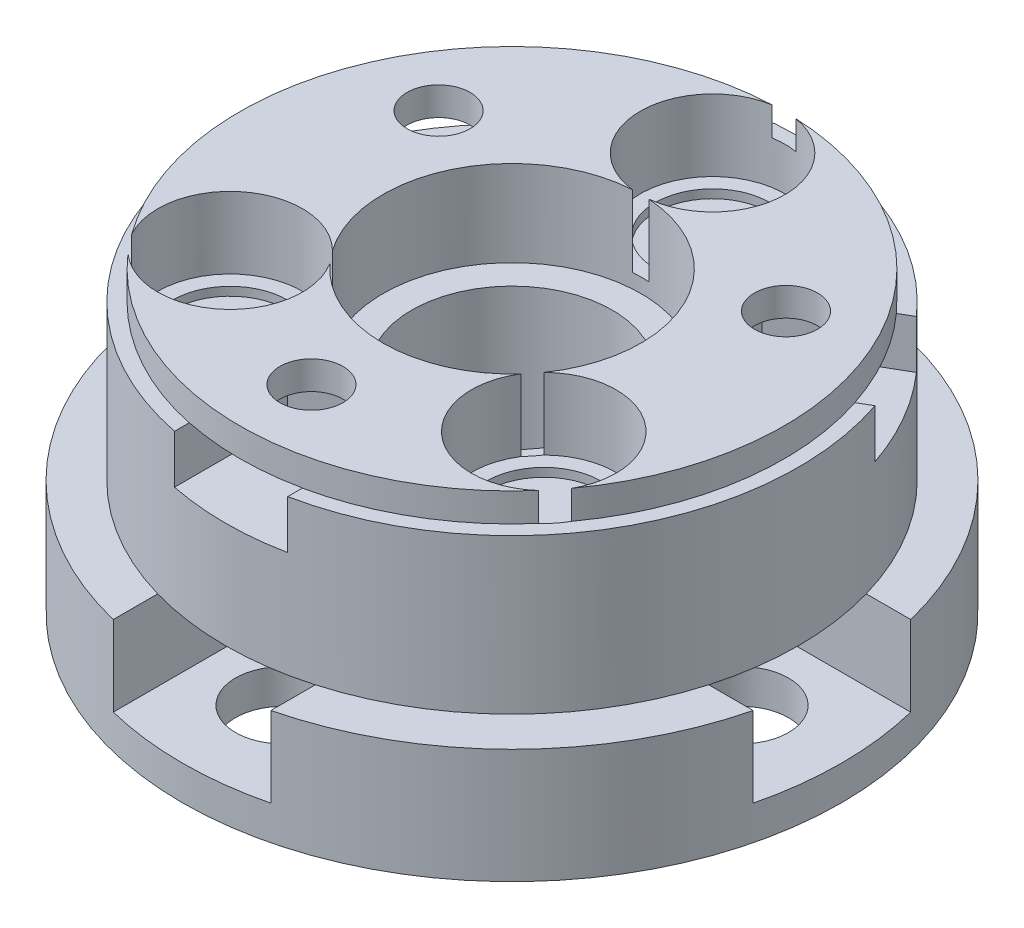
from build123d import *

# Parameters (mm, degrees)
SKETCH2_R           = 11.5
BOSS_EXTRUDE1_DEPTH = 1
SKETCH3_R           = 10
BOSS_EXTRUDE2_DEPTH = 4
SKETCH4_R           = 2.525
CUT_EXTRUDE1_DEPTH  = 17.984370982
SKETCH5_R           = 2
CUT_EXTRUDE2_DEPTH  = 0.3
CIRPATTERN1_COUNT   = 14
SKETCH7_R           = 10
SKETCH7_R_2         = 2.525
BOSS_EXTRUDE4_DEPTH = 1.5
BOSS_EXTRUDE3_DEPTH = 0.998
SKETCH8_R           = 1.1
CUT_EXTRUDE3_DEPTH  = 2.69
CUT_EXTRUDE4_DEPTH  = 1.7
CIRPATTERN2_COUNT   = 3
SKETCH11_R          = 11.5
BOSS_EXTRUDE5_DEPTH = 3
SKETCH12_R          = 1.65
CUT_EXTRUDE5_DEPTH  = 4
CUT_EXTRUDE6_DEPTH  = 2.8
CIRPATTERN3_COUNT   = 4
SKETCH16_R          = 4.5
CUT_EXTRUDE9_DEPTH  = 2
SKETCH17_R          = 3.5
CUT_EXTRUDE10_DEPTH = 18.866109191


with BuildPart() as part:
    # Sketch2 → Boss-Extrude1 (new body)
    with BuildSketch(Plane(origin=(0, 0, 0), x_dir=(1, 0, 0), z_dir=(0, 1, 0))):
        with Locations(Location((0, 0, 0), (0, 0, 270))):
            Circle(SKETCH2_R)
    extrude(amount=BOSS_EXTRUDE1_DEPTH)

    # Sketch3 → Boss-Extrude2 (add)
    with BuildSketch(Plane(origin=(0, 1, 0), x_dir=(1, 0, 0), z_dir=(0, 1, 0))):
        with Locations(Location((0, 0, 0), (0, 0, 270))):
            Circle(SKETCH3_R)
    extrude(amount=BOSS_EXTRUDE2_DEPTH)

    # Sketch4 → Cut-Extrude1 (cut, through all)
    with BuildSketch(Plane(origin=(0, 4.8958, 0), x_dir=(-1, 0, 0), z_dir=(0, -1, 0))):
        with Locations(Location((0, 7, 0), (0, 0, 90))):
            Circle(SKETCH4_R)
    cut_extrude1 = extrude(amount=-CUT_EXTRUDE1_DEPTH, mode=Mode.SUBTRACT)

    # Sketch5 → Cut-Extrude2 (cut)
    with BuildSketch(Plane(origin=(0, 4.8958, 0), x_dir=(1, 0, 0), z_dir=(0, 1, 0))):
        with Locations(Location((0, 7, 0), (0, 0, 270))):
            Circle(SKETCH5_R)
    cut_extrude2 = extrude(amount=-CUT_EXTRUDE2_DEPTH, mode=Mode.SUBTRACT)

    # CirPattern1: Cut-Extrude1, Cut-Extrude2 ×14 about axis, 11 skipped
    cirpattern1_axis = Axis((0, 5, 0), (0, -1, 0))
    add([cut_extrude1.rotate(cirpattern1_axis, i * 360 / CIRPATTERN1_COUNT) for i in range(1, CIRPATTERN1_COUNT) if i not in (1, 2, 3, 4, 6, 7, 8, 10, 11, 12, 13)], mode=Mode.SUBTRACT)
    add([cut_extrude2.rotate(cirpattern1_axis, i * 360 / CIRPATTERN1_COUNT) for i in range(1, CIRPATTERN1_COUNT) if i not in (1, 2, 3, 4, 6, 7, 8, 10, 11, 12, 13)], mode=Mode.SUBTRACT)

    # Sketch7 → Boss-Extrude4 (add)
    with BuildSketch(Plane(origin=(0, 4.8958, 0), x_dir=(1, 0, 0), z_dir=(0, 1, 0))):
        with Locations(Location((0, 0, 0), (0, 0, 270))):
            Circle(SKETCH7_R)
        with Locations(Location((5.472820377, -4.364428613, 0), (0, 0, 321.428571429))):
            Circle(SKETCH7_R_2, mode=Mode.SUBTRACT)
        with Locations(Location((-5.472820377, -4.364428613, 0), (0, 0, 90))):
            Circle(SKETCH7_R_2, mode=Mode.SUBTRACT)
        with Locations(Location((0, 7, 0), (0, 0, 90))):
            Circle(SKETCH7_R_2, mode=Mode.SUBTRACT)
    extrude(amount=BOSS_EXTRUDE4_DEPTH)

    # Sketch6 → Boss-Extrude3 (add)
    with BuildSketch(Plane(origin=(0, 6.3958, 0), x_dir=(1, 0, 0), z_dir=(0, 1, 0))):
        with BuildLine():
            ThreePointArc((-0.412808131, 9.491026786), (-2.524163057, 6.934993371), (-0.284039451, 4.491026786))
            ThreePointArc((-0.284039451, 4.491026786), (-4.054359906, 1.952476826), (-3.688321831, -2.578038415))
            ThreePointArc((-3.688321831, -2.578038415), (-6.995786073, -2.350427498), (-7.677765202, -5.594812017))
            ThreePointArc((-7.677765202, -5.594812017), (-8.559204245, 4.121895522), (-0.412808131, 9.491026786))
        make_face()
        with BuildLine():
            ThreePointArc((3.334130428, -3.022180386), (3.848206224, -6.297367788), (7.163001882, -6.240304803))
            ThreePointArc((7.163001882, -6.240304803), (0, -9.5), (-7.163001882, -6.240304803))
            ThreePointArc((-7.163001882, -6.240304803), (-3.848206224, -6.297367788), (-3.334130428, -3.022180386))
            ThreePointArc((-3.334130428, -3.022180386), (0, -4.5), (3.334130428, -3.022180386))
        make_face()
        with BuildLine():
            ThreePointArc((0.284039451, 4.491026786), (2.524163057, 6.934993371), (0.412808131, 9.491026786))
            ThreePointArc((0.412808131, 9.491026786), (8.559204245, 4.121895522), (7.677765202, -5.594812017))
            ThreePointArc((7.677765202, -5.594812017), (6.995786073, -2.350427498), (3.688321831, -2.578038415))
            ThreePointArc((3.688321831, -2.578038415), (4.054359906, 1.952476826), (0.284039451, 4.491026786))
        make_face()
    extrude(amount=BOSS_EXTRUDE3_DEPTH)

    # Sketch8 → Cut-Extrude3 (cut)
    with BuildSketch(Plane(origin=(0, 7.3938, 0), x_dir=(1, 0, 0), z_dir=(0, 1, 0))):
        with Locations(Location((0, -7, 0), (0, 0, 270))):
            Circle(SKETCH8_R)
    cut_extrude3 = extrude(amount=-CUT_EXTRUDE3_DEPTH, mode=Mode.SUBTRACT)

    # Sketch9 → Cut-Extrude4 (cut)
    with BuildSketch(Plane(origin=(0, 4.7038, 0), x_dir=(1, 0, 0), z_dir=(0, 1, 0))):
        Polygon((-1.975, -8.140266782), (-1.975, -11.329138317), (1.975, -11.329138317), (1.975, -8.140266782), (1.975, -5.859733218), (0, -4.719466437), (-1.975, -5.859733218), align=None)
    cut_extrude4 = extrude(amount=CUT_EXTRUDE4_DEPTH, mode=Mode.SUBTRACT)

    # CirPattern2: Cut-Extrude3, Cut-Extrude4 ×3 about axis
    cirpattern2_axis = Axis((0, 0, 0), (0, 1, 0))
    add([cut_extrude3.rotate(cirpattern2_axis, i * 360 / CIRPATTERN2_COUNT) for i in range(1, CIRPATTERN2_COUNT)], mode=Mode.SUBTRACT)
    add([cut_extrude4.rotate(cirpattern2_axis, i * 360 / CIRPATTERN2_COUNT) for i in range(1, CIRPATTERN2_COUNT)], mode=Mode.SUBTRACT)

    # Sketch11 → Boss-Extrude5 (add)
    with BuildSketch(Plane.XZ):
        with Locations(Location((0, 0, 0), (0, 0, 270))):
            Circle(SKETCH11_R)
    extrude(amount=BOSS_EXTRUDE5_DEPTH)

    # Sketch12 → Cut-Extrude5 (cut)
    with BuildSketch(Plane.XZ.offset(3)):
        with Locations(Location((0, 8, 0), (0, 0, 270))):
            Circle(SKETCH12_R)
    cut_extrude5 = extrude(amount=-CUT_EXTRUDE5_DEPTH, mode=Mode.SUBTRACT)

    # Sketch13 → Cut-Extrude6 (cut)
    with BuildSketch(Plane(origin=(0, 1, 0), x_dir=(1, 0, 0), z_dir=(0, 1, 0))):
        Polygon((-2.75, -9.58771324), (-2.75, -11.5), (2.75, -11.5), (2.75, -9.58771324), (2.75, -6.41228676), (0, -4.824573519), (-2.75, -6.41228676), align=None)
    cut_extrude6 = extrude(amount=-CUT_EXTRUDE6_DEPTH, mode=Mode.SUBTRACT)

    # CirPattern3: Cut-Extrude5, Cut-Extrude6 ×4 about axis
    cirpattern3_axis = Axis((0, 0, 0), (0, 1, 0))
    add([cut_extrude5.rotate(cirpattern3_axis, i * 360 / CIRPATTERN3_COUNT) for i in range(1, CIRPATTERN3_COUNT)], mode=Mode.SUBTRACT)
    add([cut_extrude6.rotate(cirpattern3_axis, i * 360 / CIRPATTERN3_COUNT) for i in range(1, CIRPATTERN3_COUNT)], mode=Mode.SUBTRACT)

    # Sketch16 → Cut-Extrude9 (cut)
    with BuildSketch(Plane(origin=(0, 6.3958, 0), x_dir=(1, 0, 0), z_dir=(0, 1, 0))):
        with Locations(Location((0, 0, 0), (0, 0, 93.618908364))):
            Circle(SKETCH16_R)
    extrude(amount=-CUT_EXTRUDE9_DEPTH, mode=Mode.SUBTRACT)

    # Sketch17 → Cut-Extrude10 (cut, through all)
    with BuildSketch(Plane(origin=(0, 4.3958, 0), x_dir=(1, 0, 0), z_dir=(0, 1, 0))):
        with Locations(Location((0, 0, 0), (0, 0, 270))):
            Circle(SKETCH17_R)
    extrude(amount=-CUT_EXTRUDE10_DEPTH, mode=Mode.SUBTRACT)


solid = part.part
